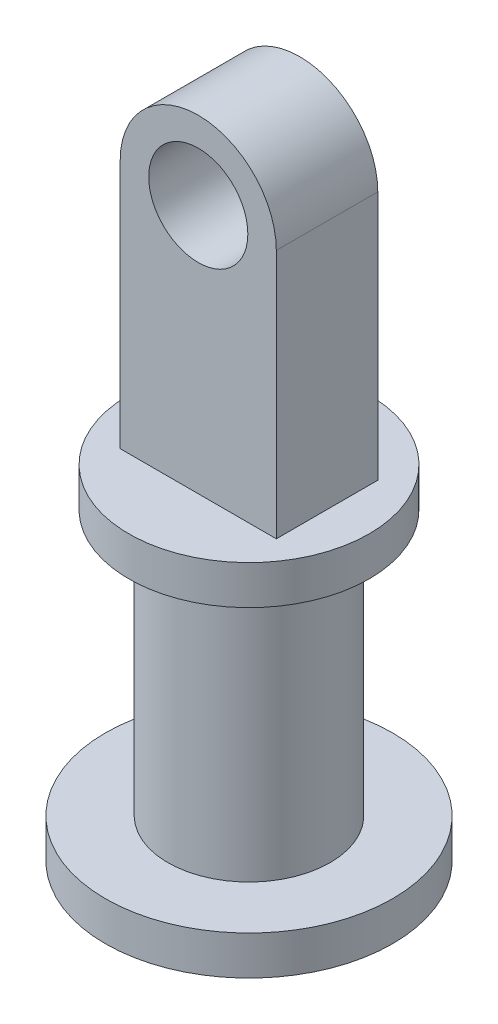
from build123d import *

# Parameters (mm, degrees)
SKETCH1_R           = 1.5875
BOSS_EXTRUDE1_DEPTH = 3.25


with BuildPart() as part:
    # Sketch1 → Boss-Extrude1 (new body)
    with BuildSketch(Plane.XY):
        with BuildLine():
            Line((2.5, 0), (2.5, -8))
            Line((2.5, -8), (-2.5, -8))
            Line((-2.5, -8), (-2.5, 0))
            ThreePointArc((-2.5, 0), (0, 2.5), (2.5, 0))
        make_face()
        Circle(SKETCH1_R, mode=Mode.SUBTRACT)
    extrude(amount=BOSS_EXTRUDE1_DEPTH)

    # Sketch4 one side → Revolve1 (revolve)
    with BuildSketch(Plane.XY.offset(1.625)):
        Polygon((2.6, -8), (0, -8), (0, -9.25), (1.35, -9.25), (1.35, -18.994831853), (4.6, -18.994831853), (4.6, -17.744831853), (2.6, -17.744831853), (2.6, -9.25), (3.85, -9.25), (3.85, -8), align=None)
    revolve(axis=Axis((0, -19.5, 1.625), (0, 1, 0)))


solid = part.part
